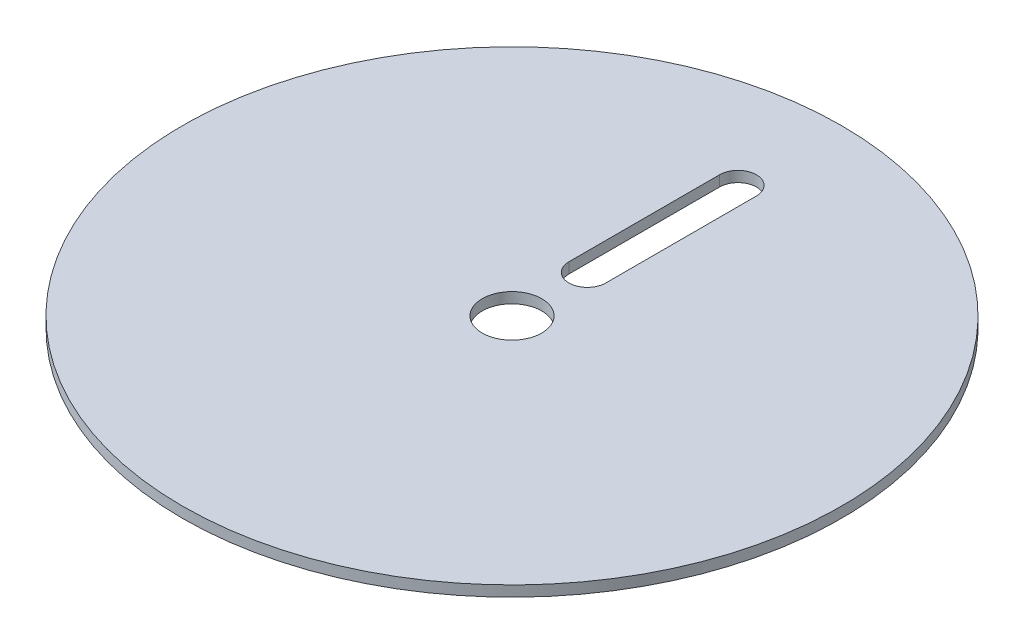
from build123d import *

# Parameters (mm, degrees)
SKETCH1_R           = 98.425
SKETCH1_R_2         = 8.89
BOSS_EXTRUDE1_DEPTH = 3.175


with BuildPart() as part:
    # Sketch1 → Boss-Extrude1 (new body)
    with BuildSketch(Plane(origin=(0, 0, 0), x_dir=(1, 0, 0), z_dir=(0, 1, 0))):
        Circle(SKETCH1_R)
        Circle(SKETCH1_R_2, mode=Mode.SUBTRACT)
        with BuildLine():
            Line((-5.5, 22.5), (-5.5, 67.5))
            ThreePointArc((-5.5, 67.5), (0, 73), (5.5, 67.5))
            Line((5.5, 67.5), (5.5, 22.5))
            ThreePointArc((5.5, 22.5), (0, 17), (-5.5, 22.5))
        make_face(mode=Mode.SUBTRACT)
    extrude(amount=BOSS_EXTRUDE1_DEPTH)


solid = part.part
